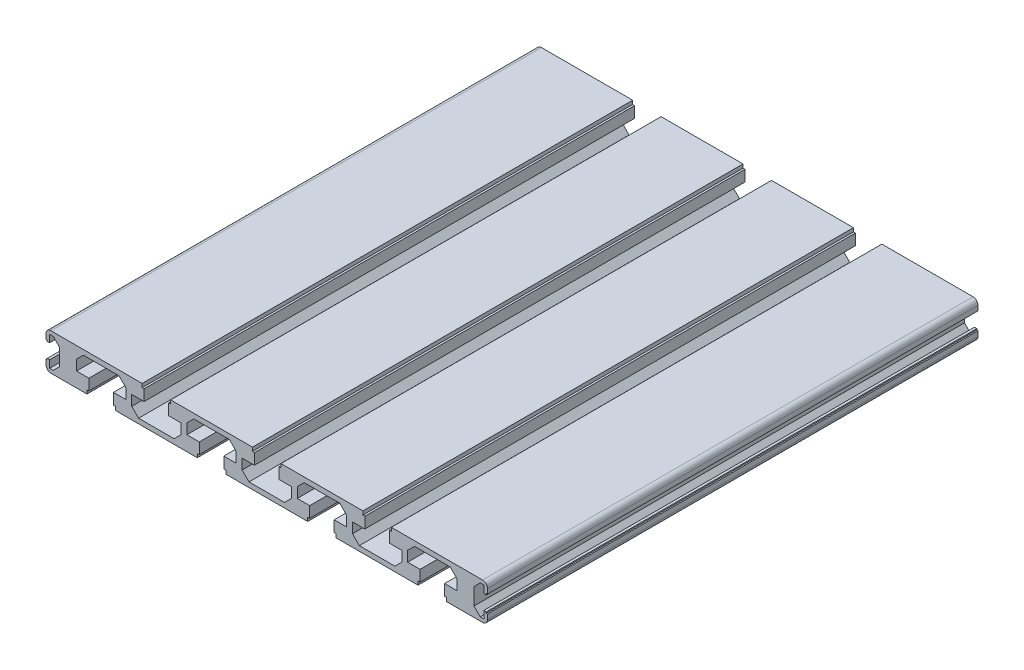
from build123d import *

# Parameters (mm, degrees)
EXTRUDE_1_DEPTH = 200


with BuildPart() as part:
    # Эскиз1 → Бобышка-Вытянуть1 (new body)
    with BuildSketch(Plane.XY):
        with BuildLine():
            Line((-85.853717104, -6.166822364), (-87.303717104, -6.166822364))
            Line((-87.303717104, -6.166822364), (-87.303717104, -3.166822364))
            Line((-87.303717104, -3.166822364), (-88.303717104, -3.166822364))
            Line((-88.303717104, -3.166822364), (-88.303717104, -3.666822364))
            Line((-88.303717104, -3.666822364), (-88.803717104, -3.666822364))
            Line((-88.803717104, -3.666822364), (-88.803717104, -5.666822356))
            ThreePointArc((-88.803717104, -5.666822356), (-88.217930664, -7.081035924), (-86.803717096, -7.666822364))
            Line((-86.803717096, -7.666822364), (-72.103717104, -7.666822364))
            Line((-72.103717104, -7.666822364), (-72.103717104, -6.166822364))
            Line((-72.103717104, -6.166822364), (-71.303717104, -6.166822364))
            Line((-71.303717104, -6.166822364), (-71.303717104, -1.666822364))
            Line((-71.303717104, -1.666822364), (-76.353717104, -1.666822364))
            Line((-76.353717104, -1.666822364), (-76.353717104, 2.533177636))
            Line((-76.353717104, 2.533177636), (-73.553717104, 5.333177636))
            Line((-73.553717104, 5.333177636), (-59.053717104, 5.333177636))
            Line((-59.053717104, 5.333177636), (-56.253717104, 2.533177636))
            Line((-56.253717104, 2.533177636), (-56.253717104, -1.666822364))
            Line((-56.253717104, -1.666822364), (-61.303717104, -1.666822364))
            Line((-61.303717104, -1.666822364), (-61.303717104, -6.166822364))
            Line((-61.303717104, -6.166822364), (-60.503717104, -6.166822364))
            Line((-60.503717104, -6.166822364), (-60.503717104, -7.666822364))
            Line((-60.503717104, -7.666822364), (-27.103717104, -7.666822364))
            Line((-27.103717104, -7.666822364), (-27.103717104, -6.166822364))
            Line((-27.103717104, -6.166822364), (-26.303717104, -6.166822364))
            Line((-26.303717104, -6.166822364), (-26.303717104, -1.666822364))
            Line((-26.303717104, -1.666822364), (-31.353717104, -1.666822364))
            Line((-31.353717104, -1.666822364), (-31.353717104, 2.533177636))
            Line((-31.353717104, 2.533177636), (-28.553717104, 5.333177636))
            Line((-28.553717104, 5.333177636), (-14.053717104, 5.333177636))
            Line((-14.053717104, 5.333177636), (-11.253717104, 2.533177636))
            Line((-11.253717104, 2.533177636), (-11.253717104, -1.666822364))
            Line((-11.253717104, -1.666822364), (-16.303717104, -1.666822364))
            Line((-16.303717104, -1.666822364), (-16.303717104, -6.166822364))
            Line((-16.303717104, -6.166822364), (-15.503717104, -6.166822364))
            Line((-15.503717104, -6.166822364), (-15.503717104, -7.666822364))
            Line((-15.503717104, -7.666822364), (17.896282896, -7.666822364))
            Line((17.896282896, -7.666822364), (17.896282896, -6.166822364))
            Line((17.896282896, -6.166822364), (18.696282896, -6.166822364))
            Line((18.696282896, -6.166822364), (18.696282896, -1.666822364))
            Line((18.696282896, -1.666822364), (13.646282896, -1.666822364))
            Line((13.646282896, -1.666822364), (13.646282896, 2.533177636))
            Line((13.646282896, 2.533177636), (16.446282896, 5.333177636))
            Line((16.446282896, 5.333177636), (30.946282896, 5.333177636))
            Line((30.946282896, 5.333177636), (33.746282896, 2.533177636))
            Line((33.746282896, 2.533177636), (33.746282896, -1.666822364))
            Line((33.746282896, -1.666822364), (28.696282896, -1.666822364))
            Line((28.696282896, -1.666822364), (28.696282896, -6.166822364))
            Line((28.696282896, -6.166822364), (29.496282896, -6.166822364))
            Line((29.496282896, -6.166822364), (29.496282896, -7.666822364))
            Line((29.496282896, -7.666822364), (62.896282896, -7.666822364))
            Line((62.896282896, -7.666822364), (62.896282896, -6.166822364))
            Line((62.896282896, -6.166822364), (63.696282896, -6.166822364))
            Line((63.696282896, -6.166822364), (63.696282896, -1.666822364))
            Line((63.696282896, -1.666822364), (58.646282896, -1.666822364))
            Line((58.646282896, -1.666822364), (58.646282896, 2.533177636))
            Line((58.646282896, 2.533177636), (61.446282896, 5.333177636))
            Line((61.446282896, 5.333177636), (75.946282896, 5.333177636))
            Line((75.946282896, 5.333177636), (78.746282896, 2.533177636))
            Line((78.746282896, 2.533177636), (78.746282896, -1.666822364))
            Line((78.746282896, -1.666822364), (73.696282896, -1.666822364))
            Line((73.696282896, -1.666822364), (73.696282896, -6.166822364))
            Line((73.696282896, -6.166822364), (74.496282896, -6.166822364))
            Line((74.496282896, -6.166822364), (74.496282896, -7.666822364))
            Line((74.496282896, -7.666822364), (89.196282888, -7.666822364))
            ThreePointArc((89.196282888, -7.666822364), (90.610496456, -7.081035924), (91.196282896, -5.666822356))
            Line((91.196282896, -5.666822356), (91.196282896, -3.666822364))
            Line((91.196282896, -3.666822364), (90.696282896, -3.666822364))
            Line((90.696282896, -3.666822364), (90.696282896, -3.166822364))
            Line((90.696282896, -3.166822364), (89.696282896, -3.166822364))
            Line((89.696282896, -3.166822364), (89.696282896, -6.166822364))
            Line((89.696282896, -6.166822364), (88.246282896, -6.166822364))
            Line((88.246282896, -6.166822364), (85.696282896, -3.616822364))
            Line((85.696282896, -3.616822364), (85.696282896, 3.283177636))
            Line((85.696282896, 3.283177636), (88.246282896, 5.833177636))
            Line((88.246282896, 5.833177636), (89.696282896, 5.833177636))
            Line((89.696282896, 5.833177636), (89.696282896, 2.833177636))
            Line((89.696282896, 2.833177636), (90.696282896, 2.833177636))
            Line((90.696282896, 2.833177636), (90.696282896, 3.333177636))
            Line((90.696282896, 3.333177636), (91.196282896, 3.333177636))
            Line((91.196282896, 3.333177636), (91.196282896, 5.333177628))
            ThreePointArc((91.196282896, 5.333177628), (90.610496456, 6.747391196), (89.196282888, 7.333177636))
            Line((89.196282888, 7.333177636), (51.996282896, 7.333177636))
            Line((51.996282896, 7.333177636), (51.996282896, 5.833177636))
            Line((51.996282896, 5.833177636), (51.196282898, 5.833177636))
            Line((51.196282898, 5.833177636), (51.196282898, 1.333177634))
            Line((51.196282898, 1.333177634), (56.246282898, 1.333177634))
            Line((56.246282898, 1.333177634), (56.246282898, -2.866822366))
            Line((56.246282898, -2.866822366), (53.446282898, -5.666822366))
            Line((53.446282898, -5.666822366), (38.946282898, -5.666822366))
            Line((38.946282898, -5.666822366), (36.146282898, -2.866822366))
            Line((36.146282898, -2.866822366), (36.146282898, 1.333177634))
            Line((36.146282898, 1.333177634), (41.196282898, 1.333177634))
            Line((41.196282898, 1.333177634), (41.196282898, 5.833177636))
            Line((41.196282898, 5.833177636), (40.396282896, 5.833177636))
            Line((40.396282896, 5.833177636), (40.396282896, 7.333177636))
            Line((40.396282896, 7.333177636), (6.996282896, 7.333177636))
            Line((6.996282896, 7.333177636), (6.996282896, 5.833177636))
            Line((6.996282896, 5.833177636), (6.196282898, 5.833177636))
            Line((6.196282898, 5.833177636), (6.196282898, 1.333177634))
            Line((6.196282898, 1.333177634), (11.246282898, 1.333177634))
            Line((11.246282898, 1.333177634), (11.246282898, -2.866822366))
            Line((11.246282898, -2.866822366), (8.446282898, -5.666822366))
            Line((8.446282898, -5.666822366), (-6.053717102, -5.666822366))
            Line((-6.053717102, -5.666822366), (-8.853717102, -2.866822366))
            Line((-8.853717102, -2.866822366), (-8.853717102, 1.333177634))
            Line((-8.853717102, 1.333177634), (-3.803717102, 1.333177634))
            Line((-3.803717102, 1.333177634), (-3.803717102, 5.833177636))
            Line((-3.803717102, 5.833177636), (-4.603717104, 5.833177636))
            Line((-4.603717104, 5.833177636), (-4.603717104, 7.333177636))
            Line((-4.603717104, 7.333177636), (-38.003717104, 7.333177636))
            Line((-38.003717104, 7.333177636), (-38.003717104, 5.833177636))
            Line((-38.003717104, 5.833177636), (-38.803717102, 5.833177636))
            Line((-38.803717102, 5.833177636), (-38.803717102, 1.333177634))
            Line((-38.803717102, 1.333177634), (-33.753717102, 1.333177634))
            Line((-33.753717102, 1.333177634), (-33.753717102, -2.866822366))
            Line((-33.753717102, -2.866822366), (-36.553717102, -5.666822366))
            Line((-36.553717102, -5.666822366), (-51.053717102, -5.666822366))
            Line((-51.053717102, -5.666822366), (-53.853717102, -2.866822366))
            Line((-53.853717102, -2.866822366), (-53.853717102, 1.333177634))
            Line((-53.853717102, 1.333177634), (-48.803717102, 1.333177634))
            Line((-48.803717102, 1.333177634), (-48.803717102, 5.833177636))
            Line((-48.803717102, 5.833177636), (-49.603717104, 5.833177636))
            Line((-49.603717104, 5.833177636), (-49.603717104, 7.333177636))
            Line((-49.603717104, 7.333177636), (-86.803717096, 7.333177636))
            ThreePointArc((-86.803717096, 7.333177636), (-88.217930664, 6.747391196), (-88.803717104, 5.333177628))
            Line((-88.803717104, 5.333177628), (-88.803717104, 3.333177636))
            Line((-88.803717104, 3.333177636), (-88.303717104, 3.333177636))
            Line((-88.303717104, 3.333177636), (-88.303717104, 2.833177636))
            Line((-88.303717104, 2.833177636), (-87.303717104, 2.833177636))
            Line((-87.303717104, 2.833177636), (-87.303717104, 5.833177636))
            Line((-87.303717104, 5.833177636), (-85.853717104, 5.833177636))
            Line((-85.853717104, 5.833177636), (-83.303717104, 3.283177636))
            Line((-83.303717104, 3.283177636), (-83.303717104, -3.616822364))
            Line((-83.303717104, -3.616822364), (-85.853717104, -6.166822364))
        make_face()
    extrude(amount=EXTRUDE_1_DEPTH)


solid = part.part
